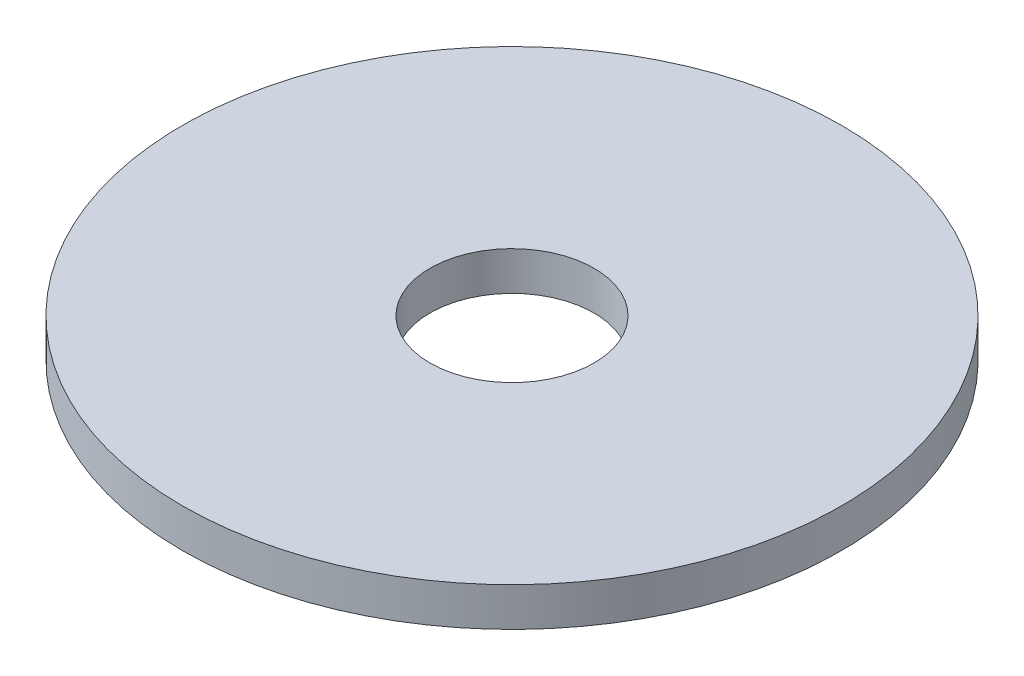
from build123d import *

# Parameters (mm, degrees)
SKETCH1_R           = 12.75
SKETCH1_R_2         = 3.175
BOSS_EXTRUDE1_DEPTH = 1.5


with BuildPart() as part:
    # Sketch1 → Boss-Extrude1 (new body)
    with BuildSketch(Plane(origin=(0, 0, 0), x_dir=(1, 0, 0), z_dir=(0, 1, 0))):
        Circle(SKETCH1_R)
        Circle(SKETCH1_R_2, mode=Mode.SUBTRACT)
    extrude(amount=BOSS_EXTRUDE1_DEPTH)


solid = part.part
